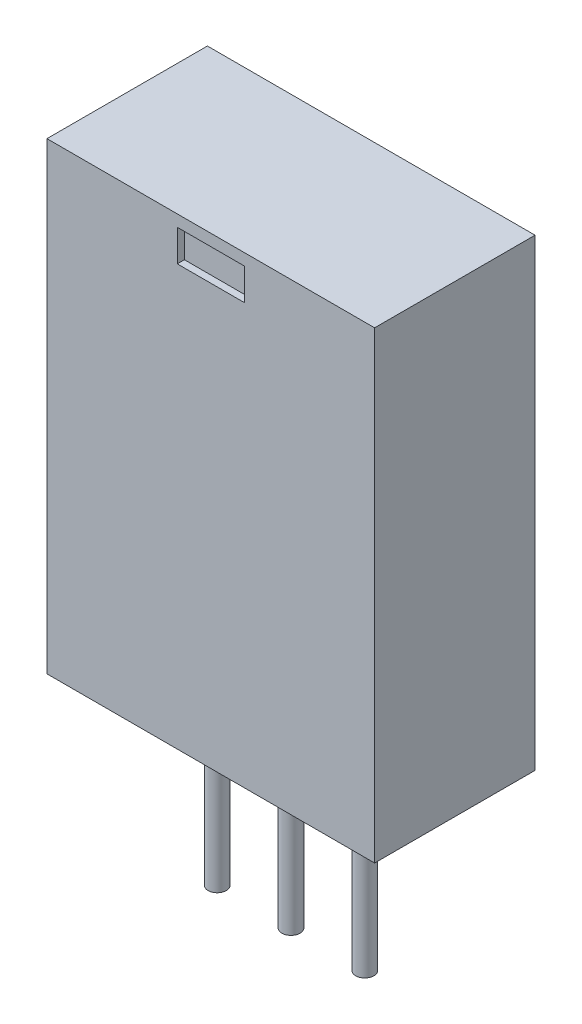
from build123d import *

# Parameters (mm, degrees)
SKETCH1_W           = 11.6713
SKETCH1_H           = 16.51
BOSS_EXTRUDE1_DEPTH = 5.715
SKETCH2_W           = 2.385044452
SKETCH2_H           = 1.128356889
CUT_EXTRUDE1_DEPTH  = 0.254
SKETCH3_R           = 0.32385
BOSS_EXTRUDE2_DEPTH = 6.35


with BuildPart() as part:
    # Sketch1 → Boss-Extrude1 (new body)
    with BuildSketch(Plane.XY):
        Rectangle(SKETCH1_W, SKETCH1_H)
    extrude(amount=BOSS_EXTRUDE1_DEPTH)

    # Sketch2 → Cut-Extrude1 (cut)
    with BuildSketch(Plane.XY.offset(5.715)):
        with Locations((0, 7.277518213)):
            Rectangle(SKETCH2_W, SKETCH2_H)
    extrude(amount=-CUT_EXTRUDE1_DEPTH, mode=Mode.SUBTRACT)

    # Sketch3 → Boss-Extrude2 (add)
    with BuildSketch(Plane.XZ.offset(8.255)):
        with Locations((-2.6289, 2.8575)):
            Circle(SKETCH3_R)
        with Locations((0, 2.8575)):
            Circle(SKETCH3_R)
        with Locations((2.6289, 2.8575)):
            Circle(SKETCH3_R)
    extrude(amount=BOSS_EXTRUDE2_DEPTH)


solid = part.part
